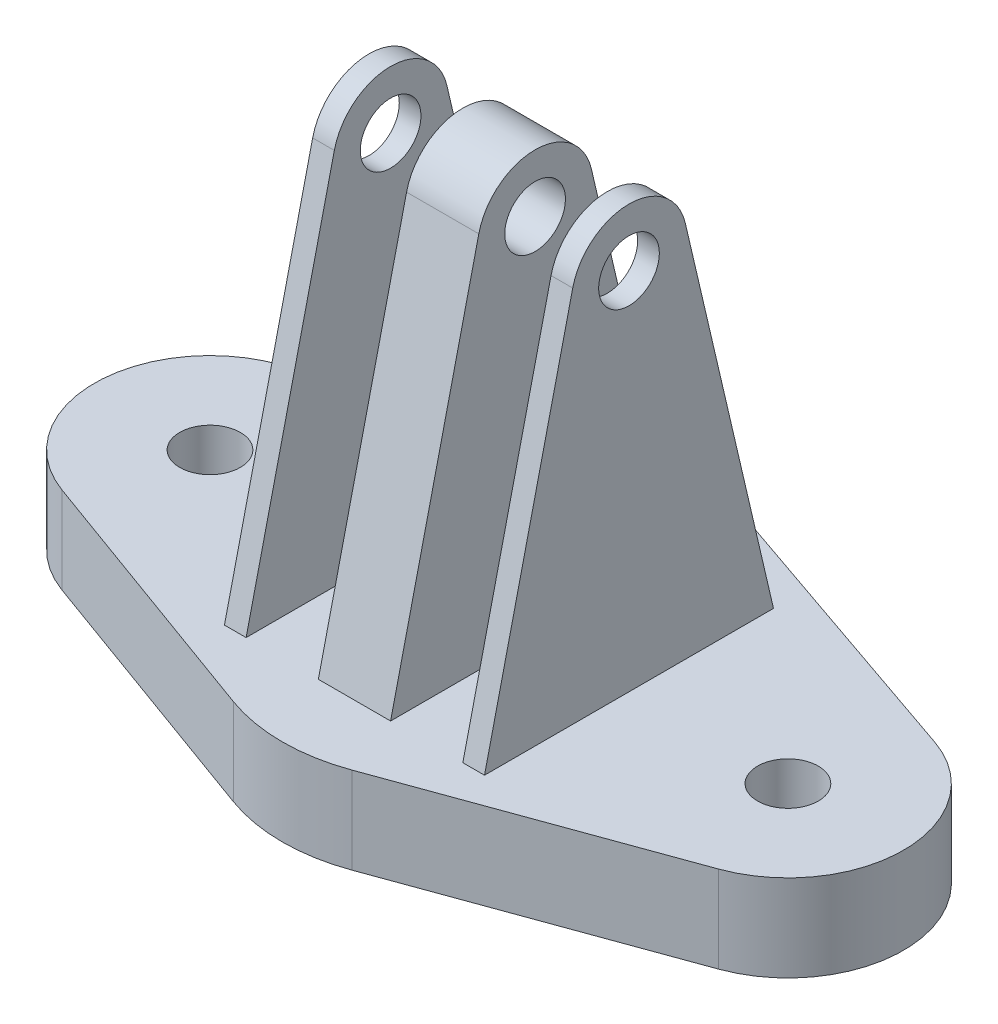
from build123d import *

# Parameters (mm, degrees)
SKETCH1_R           = 2.1
BOSS_EXTRUDE1_DEPTH = 6
SKETCH2_R           = 2.1
BOSS_EXTRUDE2_DEPTH = 9
SKETCH3_W           = 5
SKETCH3_H           = 58.48
CUT_EXTRUDE1_DEPTH  = 16


with BuildPart() as part:
    # Sketch1 → Boss-Extrude1 (new body)
    with BuildSketch(Plane(origin=(0, 0, 0), x_dir=(1, 0, 0), z_dir=(0, 1, 0))):
        with BuildLine():
            Line((22.603957871, 7.564350825), (1.952968403, 14.673263119))
            ThreePointArc((1.952968403, 14.673263119), (0.990055879, 14.917752053), (0, 15))
            Line((0, 15), (0, -15))
            ThreePointArc((0, -15), (2.077420969, -14.818812213), (4.092108053, -14.280720353))
            Line((4.092108053, -14.280720353), (22.728072035, -7.520480235))
            ThreePointArc((22.728072035, -7.520480235), (27.999729231, 0.065819743), (22.603957871, 7.564350825))
        make_face()
        with Locations((20, 0)):
            Circle(SKETCH1_R, mode=Mode.SUBTRACT)
    boss_extrude1 = extrude(amount=BOSS_EXTRUDE1_DEPTH)

    # Mirror1: Boss-Extrude1 across plane
    add(boss_extrude1.mirror(Plane(origin=(0, 6, -15), x_dir=(0, 0, 1), z_dir=(1, 0, 0))))

    # Sketch2 → Boss-Extrude2 (add, symmetric)
    with BuildSketch(Plane(origin=(0, 0, 0), x_dir=(0, 0, -1), z_dir=(1, 0, 0))):
        with BuildLine():
            Line((-10, 6), (-3.895258642, 32.149373472))
            ThreePointArc((-3.895258642, 32.149373472), (0, 35.24), (3.895258642, 32.149373472))
            Line((3.895258642, 32.149373472), (10, 6))
            Line((10, 6), (-10, 6))
        make_face()
        with Locations((0, 31.24)):
            Circle(SKETCH2_R, mode=Mode.SUBTRACT)
    extrude(amount=BOSS_EXTRUDE2_DEPTH, both=True)

    # Sketch3 → Cut-Extrude1 (cut, symmetric)
    with BuildSketch(Plane.XY):
        with Locations((-5, 35.24)):
            Rectangle(SKETCH3_W, SKETCH3_H)
    cut_extrude1 = extrude(amount=CUT_EXTRUDE1_DEPTH, both=True, mode=Mode.SUBTRACT)

    # Mirror2: Cut-Extrude1 across plane
    add(cut_extrude1.mirror(Plane(origin=(0, 0, 0), x_dir=(0, 0, 1), z_dir=(1, 0, 0))), mode=Mode.SUBTRACT)


solid = part.part
